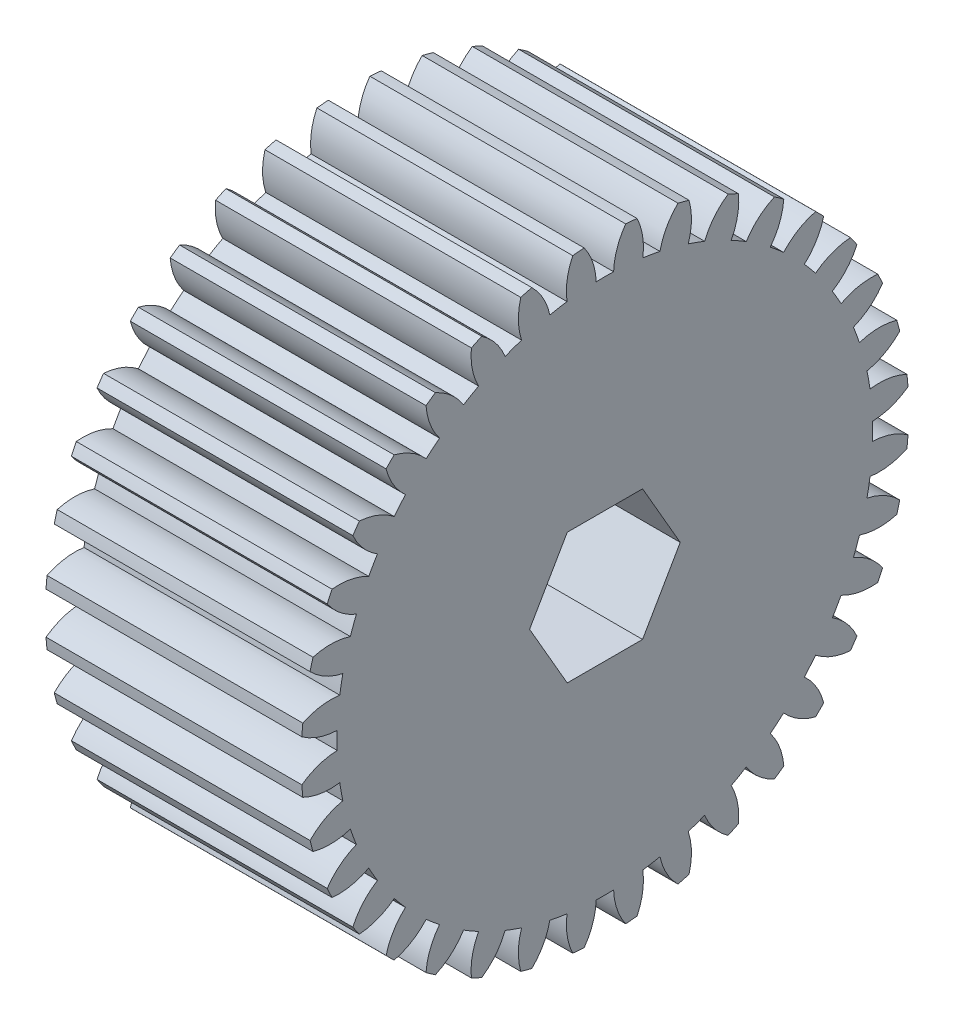
from build123d import *

# Parameters (mm, degrees)
SKETCH1_R           = 30.1625
SKETCH1_R_2         = 28.575
SKETCH1_R_3         = 26.590625
BOSS_EXTRUDE1_DEPTH = 25.4
CUT_EXTRUDE1_DEPTH  = 50.645874073
CIRPATTERN1_COUNT   = 36
CUT_EXTRUDE2_DEPTH  = 50.560048979


with BuildPart() as part:
    # Sketch1 → Boss-Extrude1 (new body)
    with BuildSketch(Plane(origin=(0, 0, 0), x_dir=(0, 0, -1), z_dir=(1, 0, 0))):
        Circle(SKETCH1_R)
        Circle(SKETCH1_R_2, mode=Mode.SUBTRACT)
        Circle(SKETCH1_R_2)
        Circle(SKETCH1_R_3, mode=Mode.SUBTRACT)
        Circle(SKETCH1_R_3)
    extrude(amount=BOSS_EXTRUDE1_DEPTH)

    # Sketch2 → Cut-Extrude1 (cut, through all)
    with BuildSketch(Plane(origin=(25.4, 0, 0), x_dir=(0, 0, -1), z_dir=(1, 0, 0))):
        with BuildLine():
            ThreePointArc((-0.865646893, 26.576530875), (-1.377980861, 28.879960006), (-2.693693877, 30.838829864))
            ThreePointArc((-2.693693877, 30.838829864), (0, 30.95625), (2.693693877, 30.838829864))
            ThreePointArc((2.693693877, 30.838829864), (1.377980861, 28.879960006), (0.865646893, 26.576530875))
            ThreePointArc((0.865646893, 26.576530875), (0, 26.590625), (-0.865646893, 26.576530875))
        make_face()
    cut_extrude1 = extrude(amount=-CUT_EXTRUDE1_DEPTH, mode=Mode.SUBTRACT)

    # CirPattern1: Cut-Extrude1 ×36 about axis
    cirpattern1_axis = Axis((0, 0, 0), (1, 0, 0))
    for i in range(1, CIRPATTERN1_COUNT):
        add(cut_extrude1.rotate(cirpattern1_axis, i * 360 / CIRPATTERN1_COUNT), mode=Mode.SUBTRACT)

    # Sketch3 → Cut-Extrude2 (cut, through all)
    with BuildSketch(Plane(origin=(25.4, 0, 0), x_dir=(0, 0, -1), z_dir=(1, 0, 0))):
        Polygon((3.739497694, 6.477), (-3.739497694, 6.477), (-7.478995387, 0), (-3.739497694, -6.477), (3.739497694, -6.477), (7.478995387, 0), align=None)
    extrude(amount=-CUT_EXTRUDE2_DEPTH, mode=Mode.SUBTRACT)


solid = part.part
